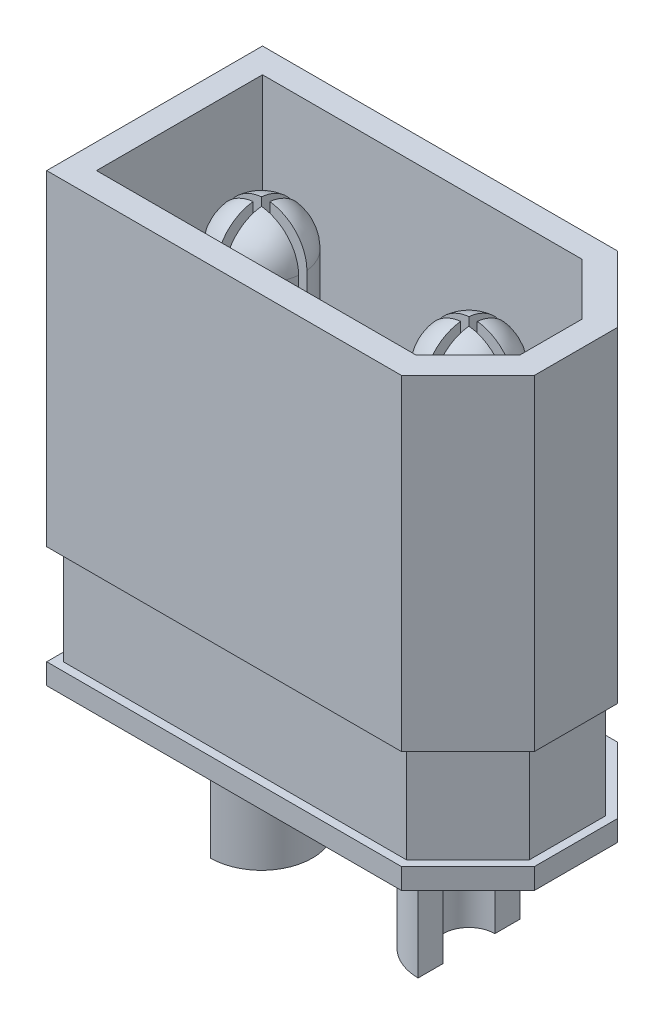
from build123d import *

# Parameters (mm, degrees)
SHAPE_DEPTH         = 10.75
CUT_EXTRUDE1_DEPTH  = 6.75
CUT_EXTRUDE2_REACH  = 6
FILLET1_R           = 0.2
SKETCH4_R           = 1
BOSS_EXTRUDE2_DEPTH = 6.1
FILLET2_R           = 1
SKETCH5_W           = 0.2
SKETCH5_H           = 2
SKETCH5_W_2         = 2
SKETCH5_H_2         = 0.2
CUT_EXTRUDE3_DEPTH  = 6.75
CUT_EXTRUDE4_DEPTH  = 2.4
CUT_EXTRUDE5_DEPTH  = 1
SKETCH7_R           = 1.225
SKETCH7_R_2         = 0.625
BOSS_EXTRUDE3_DEPTH = 4
SKETCH9_W           = 1.225
SKETCH9_H           = 2.45
CUT_EXTRUDE6_DEPTH  = 2.3


with BuildPart() as part:
    # Sketch1 → Shape (new body)
    with BuildSketch(Plane(origin=(0, 0, 0), x_dir=(1, 0, 0), z_dir=(0, 1, 0))):
        Polygon((5.075, -1), (5.075, 1), (3.475, 2.6), (-5.075, 2.6), (-5.075, -2.6), (3.475, -2.6), align=None)
    extrude(amount=SHAPE_DEPTH)

    # Sketch2 → Cut-Extrude1 (cut)
    with BuildSketch(Plane(origin=(0, 10.75, 0), x_dir=(1, 0, 0), z_dir=(0, 1, 0))):
        Polygon((3.226471863, -2), (4.475, -0.751471863), (4.475, 0.751471863), (3.226471863, 2), (-4.475, 2), (-4.475, -2), align=None)
    extrude(amount=-CUT_EXTRUDE1_DEPTH, mode=Mode.SUBTRACT)

    # Sketch3 → Cut-Extrude2 (cut, up to next)
    with BuildSketch(Plane(origin=(0, 4, 0), x_dir=(1, 0, 0), z_dir=(0, 1, 0)), mode=Mode.PRIVATE) as cut_extrude2_sk1:
        with BuildLine():
            Line((-1.675378875, -1.6), (1.675378875, -1.6))
            ThreePointArc((1.675378875, -1.6), (0.7, 0), (1.675378875, 1.6))
            Line((1.675378875, 1.6), (-1.675378875, 1.6))
            ThreePointArc((-1.675378875, 1.6), (-0.963068312, 0.936931688), (-0.7, 0))
            ThreePointArc((-0.7, 0), (-0.963068312, -0.936931688), (-1.675378875, -1.6))
        make_face()
    cut_extrude2_tool1 = extrude(cut_extrude2_sk1.sketch, amount=-CUT_EXTRUDE2_REACH, mode=Mode.PRIVATE) & part.part
    add(cut_extrude2_tool1.solids().sort_by_distance((0, 4, 0))[0], mode=Mode.SUBTRACT)

    # Fillet1
    fillet1_edges = [part.edges().sort_by_distance(p)[0] for p in [
        (1.675378875, 2, 1.6),
        (-1.675378875, 2, 1.6),
        (-1.675378875, 2, -1.6),
        (1.675378875, 2, -1.6),
    ]]
    fillet(fillet1_edges, radius=FILLET1_R)

    # Sketch4 → Boss-Extrude2 (add)
    with BuildSketch(Plane(origin=(0, 4, 0), x_dir=(1, 0, 0), z_dir=(0, 1, 0))):
        with Locations((-2.5, 0)):
            Circle(SKETCH4_R)
        with Locations((2.5, 0)):
            Circle(SKETCH4_R)
    extrude(amount=BOSS_EXTRUDE2_DEPTH)

    # Fillet2
    fillet2_edges = [part.edges().sort_by_distance(p)[0] for p in [
        (-3.5, 10.1, 0),
        (1.5, 10.1, 0),
    ]]
    fillet(fillet2_edges, radius=FILLET2_R)

    # Sketch5 → Cut-Extrude3 (cut)
    with BuildSketch(Plane(origin=(0, 10.75, 0), x_dir=(1, 0, 0), z_dir=(0, 1, 0))):
        with Locations((-2.5, 0)):
            Rectangle(SKETCH5_W, SKETCH5_H)
        with Locations((-2.5, 0)):
            Rectangle(SKETCH5_W_2, SKETCH5_H_2)
        with Locations((2.5, 0)):
            Rectangle(SKETCH5_W_2, SKETCH5_H_2)
        with Locations((2.5, 0)):
            Rectangle(SKETCH5_W, SKETCH5_H)
    extrude(amount=-CUT_EXTRUDE3_DEPTH, mode=Mode.SUBTRACT)

    # Sketch6 → Cut-Extrude4 (cut)
    with BuildSketch(Plane(origin=(0, 0.5, 0), x_dir=(-1, 0, 0), z_dir=(0, -1, 0))):
        Polygon((-5.075, -1), (-3.475, -2.6), (5.075, -2.6), (5.075, 2.6), (-3.475, 2.6), (-5.075, 1), align=None)
        Polygon((-4.875, -0.917157288), (-3.392157288, -2.4), (4.875, -2.4), (4.875, 2.4), (-3.392157288, 2.4), (-4.875, 0.917157288), align=None, mode=Mode.SUBTRACT)
    extrude(amount=-CUT_EXTRUDE4_DEPTH, mode=Mode.SUBTRACT)

    # Sketch8 → Cut-Extrude5 (cut)
    with BuildSketch(Plane.XZ):
        Polygon((-4.475, -2), (-4.475, 2), (3.226471863, 2), (4.475, 0.751471863), (4.475, -0.751471863), (3.226471863, -2), align=None)
    extrude(amount=-CUT_EXTRUDE5_DEPTH, mode=Mode.SUBTRACT)

    # Sketch7 → Boss-Extrude3 (add)
    with BuildSketch(Plane.XZ.offset(-1)):
        with Locations((-2.5, 0)):
            Circle(SKETCH7_R)
        with Locations((-2.5, 0)):
            Circle(SKETCH7_R_2, mode=Mode.SUBTRACT)
        with Locations((2.5, 0)):
            Circle(SKETCH7_R)
        with Locations((2.5, 0)):
            Circle(SKETCH7_R_2, mode=Mode.SUBTRACT)
    extrude(amount=BOSS_EXTRUDE3_DEPTH)

    # Sketch9 → Cut-Extrude6 (cut)
    with BuildSketch(Plane.XZ.offset(3)):
        with Locations((-3.1125, 0)):
            Rectangle(SKETCH9_W, SKETCH9_H)
        with Locations((3.1125, 0)):
            Rectangle(SKETCH9_W, SKETCH9_H)
    extrude(amount=-CUT_EXTRUDE6_DEPTH, mode=Mode.SUBTRACT)


solid = part.part
